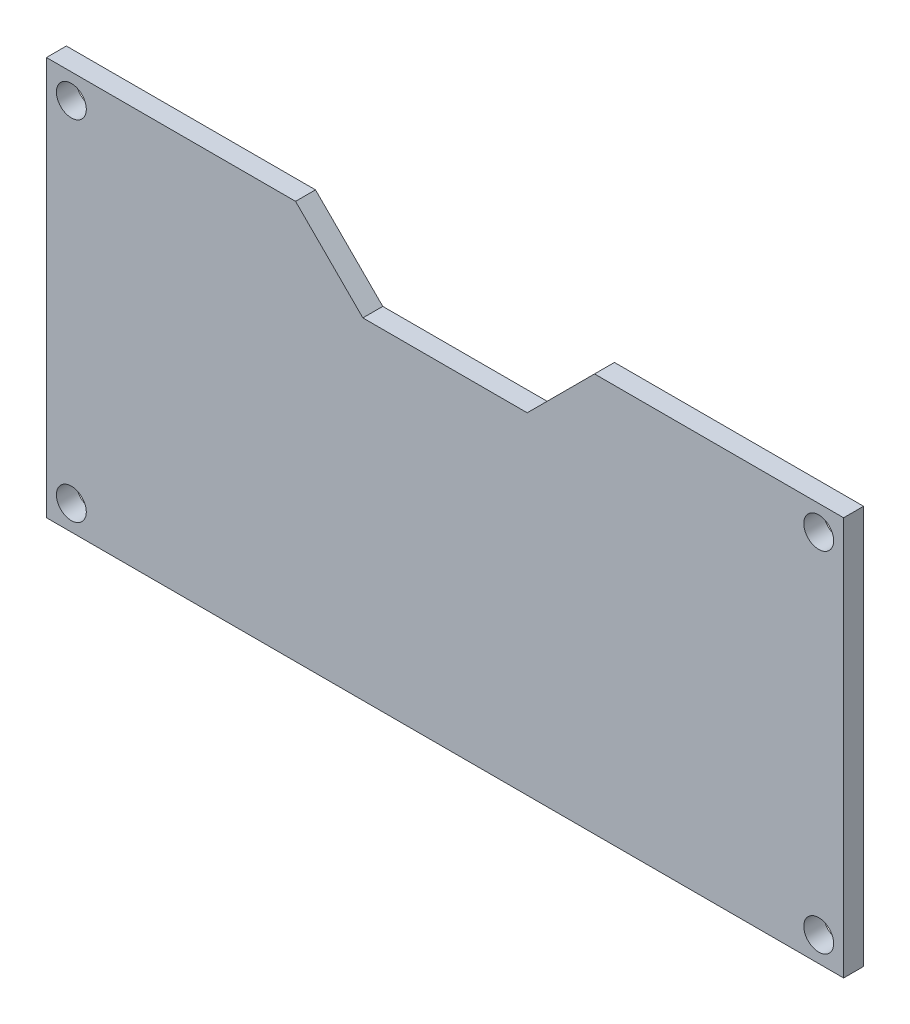
from build123d import *

# Parameters (mm, degrees)
ESQUISSE1_W             = 80
ESQUISSE1_H             = 40
BOSS_EXTRU_1_DEPTH      = 2
ESQUISSE2_R             = 1.5
ENL_V_MAT_EXTRU_1_DEPTH = 2
ENL_V_MAT_EXTRU_2_DEPTH = 10


with BuildPart() as part:
    # Esquisse1 → Boss.-Extru.1 (new body)
    with BuildSketch(Plane.XY):
        with Locations((40, 20)):
            Rectangle(ESQUISSE1_W, ESQUISSE1_H)
    extrude(amount=BOSS_EXTRU_1_DEPTH)

    # Esquisse2 → Enlèv. mat.-Extru.1 (cut)
    with BuildSketch(Plane.XY.offset(2)):
        with Locations((2.5, 37.5)):
            Circle(ESQUISSE2_R)
        with Locations((77.5, 37.5)):
            Circle(ESQUISSE2_R)
        with Locations((2.5, 2.5)):
            Circle(ESQUISSE2_R)
        with Locations((77.5, 2.5)):
            Circle(ESQUISSE2_R)
    extrude(amount=-ENL_V_MAT_EXTRU_1_DEPTH, mode=Mode.SUBTRACT)

    # Esquisse3 → Enlèv. mat.-Extru.2 (cut)
    with BuildSketch(Plane(origin=(0, 0, 0), x_dir=(-1, 0, 0), z_dir=(0, 0, -1))):
        Polygon((-25, 40), (-55, 40), (-48.246308582, 33.246308582), (-31.753691418, 33.246308582), align=None)
    extrude(amount=-ENL_V_MAT_EXTRU_2_DEPTH, mode=Mode.SUBTRACT)


solid = part.part
